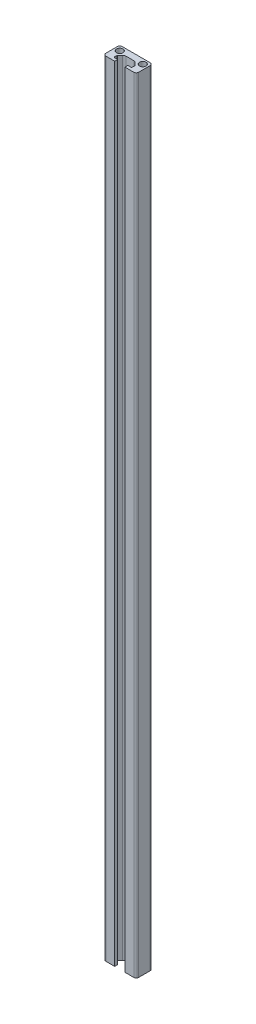
from build123d import *

# Parameters (mm, degrees)
SKETCH1_R           = 2
BOSS_EXTRUDE1_DEPTH = 477


with BuildPart() as part:
    # Sketch1 → Boss-Extrude1 (new body)
    with BuildSketch(Plane(origin=(0, 238.5, 0), x_dir=(1, 0, 0), z_dir=(0, 1, 0))):
        with BuildLine():
            Line((-3.1, 1.8), (-4.95, 1.8))
            ThreePointArc((-4.95, 1.8), (-5.303553391, 1.946446609), (-5.45, 2.3))
            Line((-5.45, 2.3), (-5.45, 3.692893219))
            ThreePointArc((-5.45, 3.692893219), (-5.411939766, 3.884234935), (-5.303553391, 4.046446609))
            Line((-5.303553391, 4.046446609), (-3.835786438, 5.514213562))
            ThreePointArc((-3.835786438, 5.514213562), (-3.18693974, 5.947759065), (-2.421572875, 6.1))
            Line((-2.421572875, 6.1), (2.421572875, 6.1))
            ThreePointArc((2.421572875, 6.1), (3.18693974, 5.947759065), (3.835786438, 5.514213562))
            Line((3.835786438, 5.514213562), (5.303553391, 4.046446609))
            ThreePointArc((5.303553391, 4.046446609), (5.411939766, 3.884234935), (5.45, 3.692893219))
            Line((5.45, 3.692893219), (5.45, 2.3))
            ThreePointArc((5.45, 2.3), (5.303553391, 1.946446609), (4.95, 1.8))
            Line((4.95, 1.8), (3.1, 1.8))
            Line((3.1, 1.8), (3.1, 0))
            Line((3.1, 0), (8.5, 0))
            ThreePointArc((8.5, 0), (9.560660172, 0.439339828), (10, 1.5))
            Line((10, 1.5), (10, 8.5))
            ThreePointArc((10, 8.5), (9.560660172, 9.560660172), (8.5, 10))
            Line((8.5, 10), (-8.5, 10))
            ThreePointArc((-8.5, 10), (-9.560660172, 9.560660172), (-10, 8.5))
            Line((-10, 8.5), (-10, 1.5))
            ThreePointArc((-10, 1.5), (-9.560660172, 0.439339828), (-8.5, 0))
            Line((-8.5, 0), (-3.1, 0))
            Line((-3.1, 0), (-3.1, 1.8))
        make_face()
        with Locations((-7, 7)):
            Circle(SKETCH1_R, mode=Mode.SUBTRACT)
        with Locations((7, 7)):
            Circle(SKETCH1_R, mode=Mode.SUBTRACT)
    extrude(amount=-BOSS_EXTRUDE1_DEPTH)


solid = part.part
